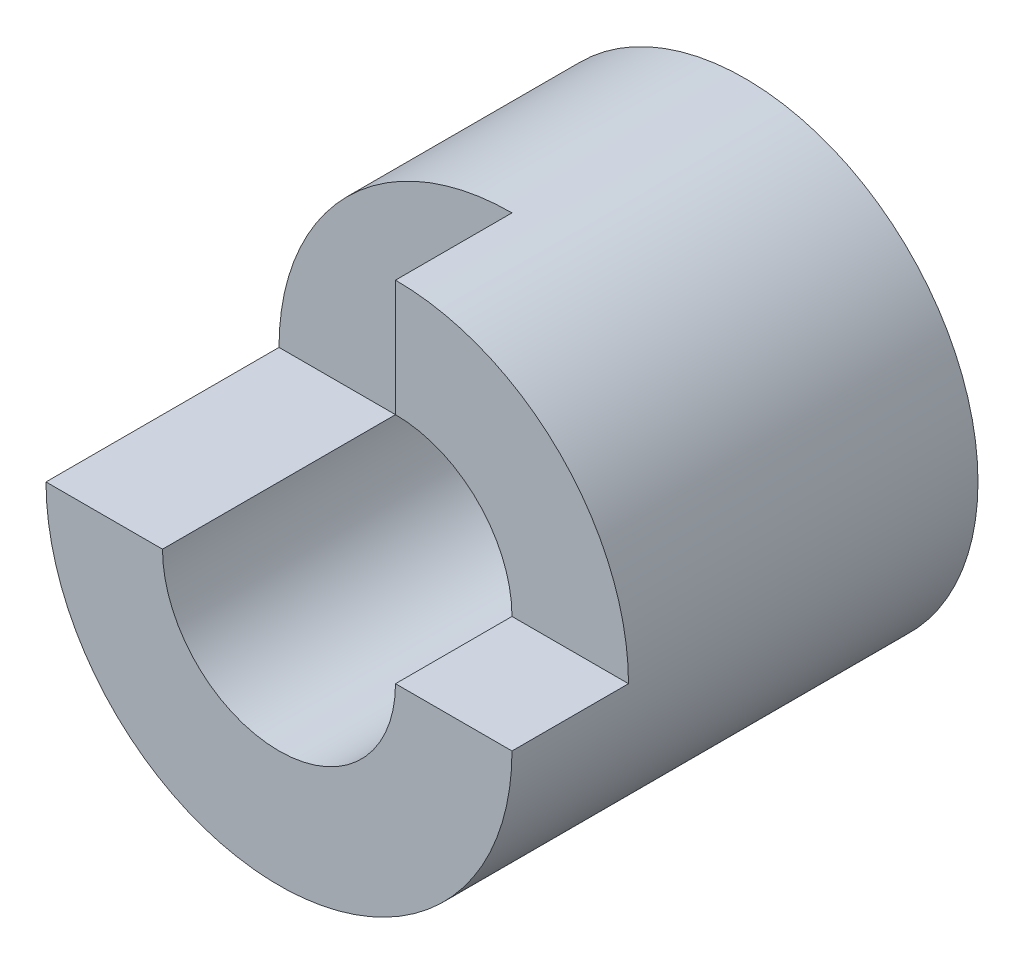
from build123d import *

# Parameters (mm, degrees)
SKETCH1_R               = 20
BOSS_EXTRUDE1_DEPTH     = 40
CUT_EXTRUDE1_DEPTH      = 40
CUT_EXTRUDE1_DEPTH_BACK = 40
SKETCH2_W               = 10
SKETCH2_H               = 20
CUT_EXTRUDE2_DEPTH      = 40
CUT_EXTRUDE2_DEPTH_BACK = 40
SKETCH3_R               = 10
CUT_EXTRUDE3_DEPTH      = 10


with BuildPart() as part:
    # Sketch1 → Boss-Extrude1 (new body)
    with BuildSketch(Plane.XY):
        Circle(SKETCH1_R)
    extrude(amount=BOSS_EXTRUDE1_DEPTH)

    # Sketch2 → Cut-Extrude1 (cut, two sides: drawn at the far end of the back side and taken through both)
    with BuildSketch(Plane(origin=(0, 0, 0), x_dir=(0, 0, -1), z_dir=(1, 0, 0)).offset(-CUT_EXTRUDE1_DEPTH_BACK)):
        with Locations((-35, 10)):
            Rectangle(SKETCH2_W, SKETCH2_H)
    extrude(amount=CUT_EXTRUDE1_DEPTH + CUT_EXTRUDE1_DEPTH_BACK, mode=Mode.SUBTRACT)

    # Sketch3 → Cut-Extrude2 (cut, two sides: drawn at the far end of the back side and taken through both)
    with BuildSketch(Plane.XY.offset(30).offset(-CUT_EXTRUDE2_DEPTH_BACK)):
        Circle(SKETCH3_R)
    extrude(amount=CUT_EXTRUDE2_DEPTH + CUT_EXTRUDE2_DEPTH_BACK, mode=Mode.SUBTRACT)

    # Sketch4 → Cut-Extrude3 (cut)
    with BuildSketch(Plane.XY.offset(30)):
        with BuildLine():
            Line((-20, 0), (-10, 0))
            ThreePointArc((-10, 0), (-7.071067812, 7.071067812), (0, 10))
            Line((0, 10), (0, 20))
            ThreePointArc((0, 20), (-14.142135624, 14.142135624), (-20, 0))
        make_face()
    extrude(amount=-CUT_EXTRUDE3_DEPTH, mode=Mode.SUBTRACT)


solid = part.part
